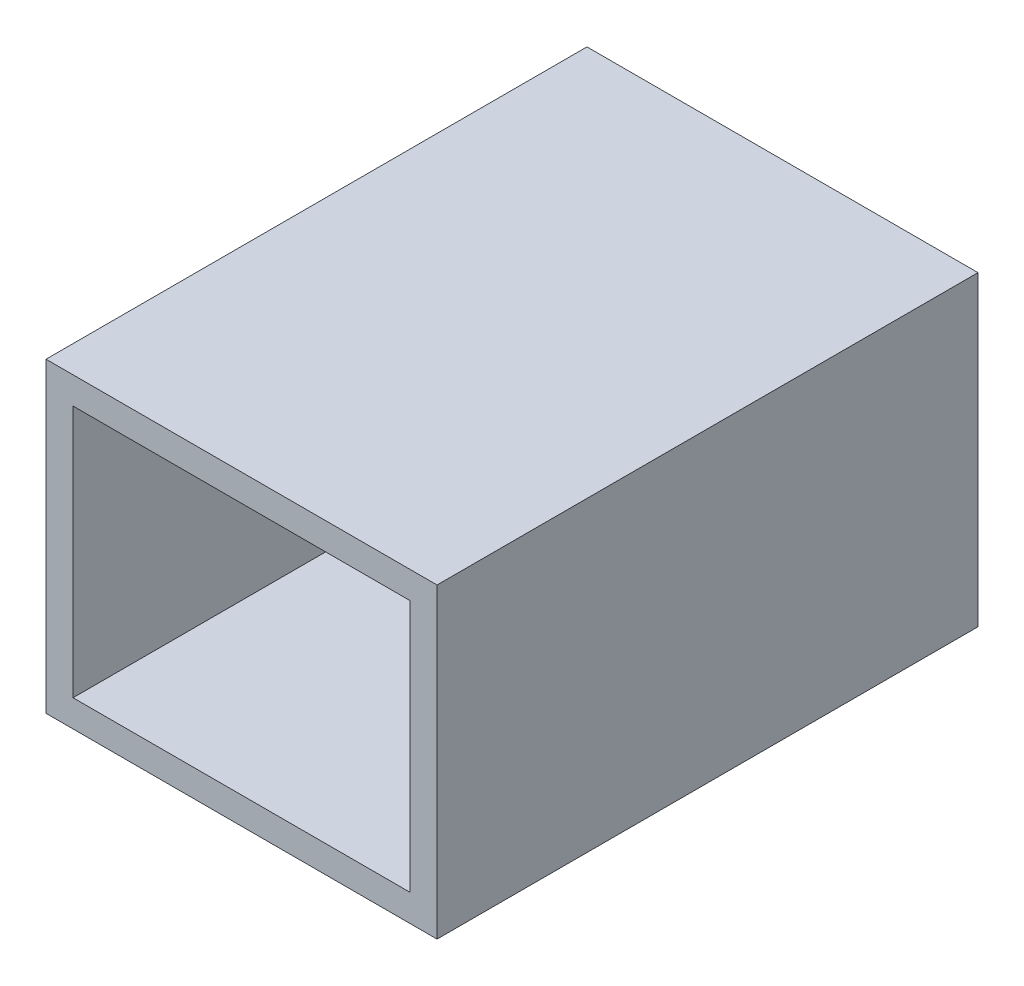
from build123d import *

# Parameters (mm, degrees)
CROQUIS1_W              = 144.567109546
CROQUIS1_H              = 113.391382114
SALIENTE_EXTRUIR1_DEPTH = 200
VACIADO2_T              = -10


with BuildPart() as part:
    # Croquis1 → Saliente-Extruir1 (new body)
    with BuildSketch(Plane.XY):
        Rectangle(CROQUIS1_W, CROQUIS1_H)
    extrude(amount=SALIENTE_EXTRUIR1_DEPTH)

    # Vaciado2
    vaciado2_openings = [part.faces().sort_by_distance(p)[0] for p in [
        (0, 0, 200),
    ]]
    offset(amount=VACIADO2_T, openings=vaciado2_openings, kind=Kind.INTERSECTION)


solid = part.part
